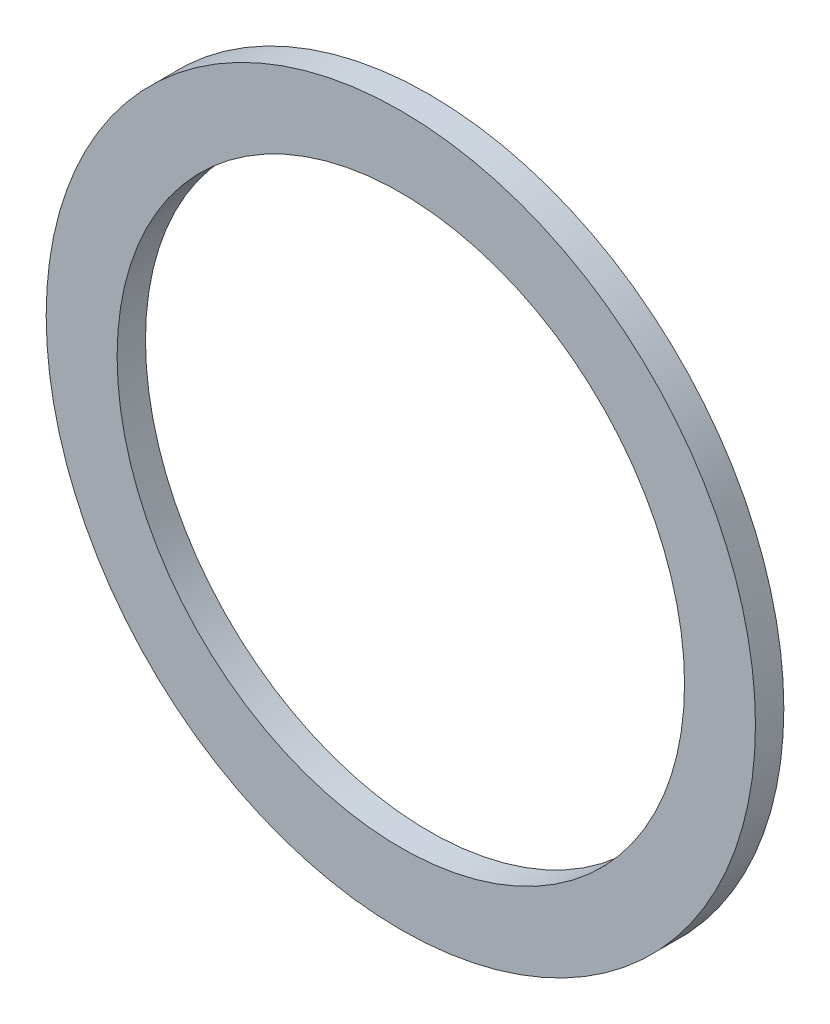
from build123d import *


with BuildPart() as part:
    # Эскиз2 → Повернуть1 (revolve)
    with BuildSketch(Plane(origin=(0, 0, 0), x_dir=(1, 0, 0), z_dir=(0, 1, 0))):
        with BuildLine():
            Line((-50, 0), (-40, 0))
            Line((-40, 0), (-40, 4))
            Line((-40, 4), (-42.401923789, 4))
            ThreePointArc((-42.401923789, 4), (-45, 2.5), (-47.598076211, 4))
            Line((-47.598076211, 4), (-50, 4))
            Line((-50, 4), (-50, 0))
        make_face()
    revolve(axis=Axis((0, 0, 0), (0, 0, -1)))


solid = part.part
